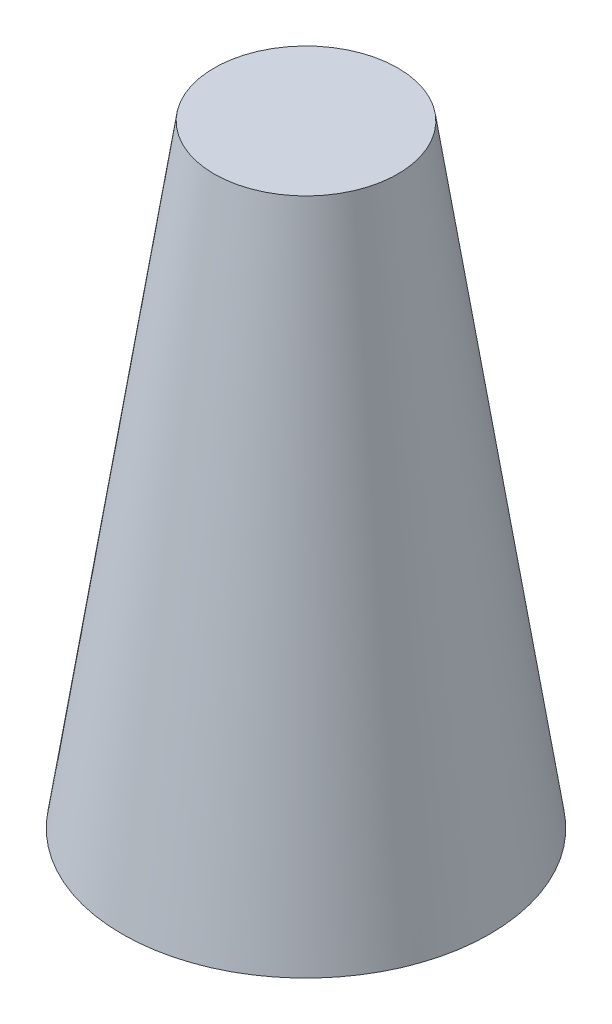
from build123d import *


with BuildPart() as part:
    # Sketch3 → Revolve1 (revolve)
    with BuildSketch(Plane.XY):
        with BuildLine():
            Line((-41.971552217, 86.483404529), (-54.944062896, 0))
            Line((-54.944062896, 0), (-60, 0))
            Line((-60, 0), (-30, 200))
            Line((-30, 200), (0, 200))
            Line((0, 200), (0, 195))
            Line((0, 195), (-17.082188688, 195))
            ThreePointArc((-17.082188688, 195), (-23.607752062, 192.577402104), (-26.971552217, 186.483404529))
            Line((-26.971552217, 186.483404529), (-41.971552217, 86.483404529))
        make_face()
    revolve(axis=Axis((0, 0, 0), (0, 1, 0)))


solid = part.part
